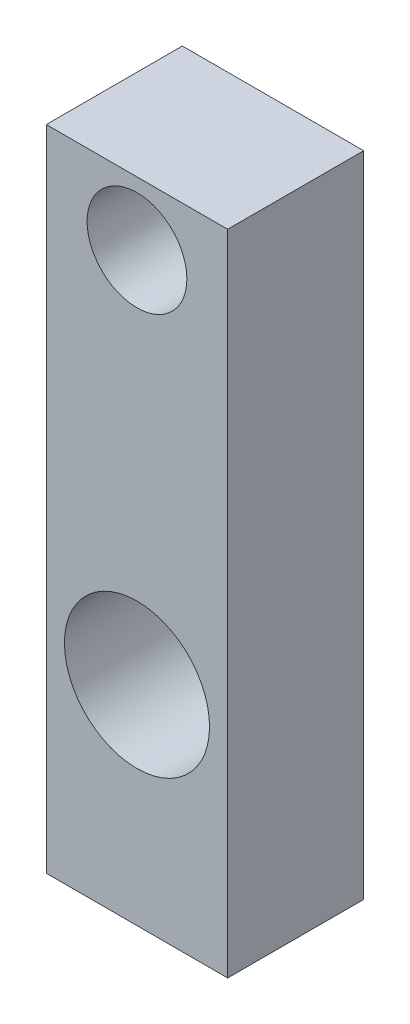
from build123d import *

# Parameters (mm, degrees)
ESQUISSE1_W        = 40
ESQUISSE1_H        = 143
ESQUISSE1_R        = 16
ESQUISSE1_R_2      = 11
BOSS_EXTRU_1_DEPTH = 30


with BuildPart() as part:
    # Esquisse1 → Boss.-Extru.1 (new body)
    with BuildSketch(Plane.XY):
        with Locations((20, 71.5)):
            Rectangle(ESQUISSE1_W, ESQUISSE1_H)
        with Locations((20, 46)):
            Circle(ESQUISSE1_R, mode=Mode.SUBTRACT)
        with Locations((20, 129)):
            Circle(ESQUISSE1_R_2, mode=Mode.SUBTRACT)
    extrude(amount=BOSS_EXTRU_1_DEPTH)


solid = part.part
